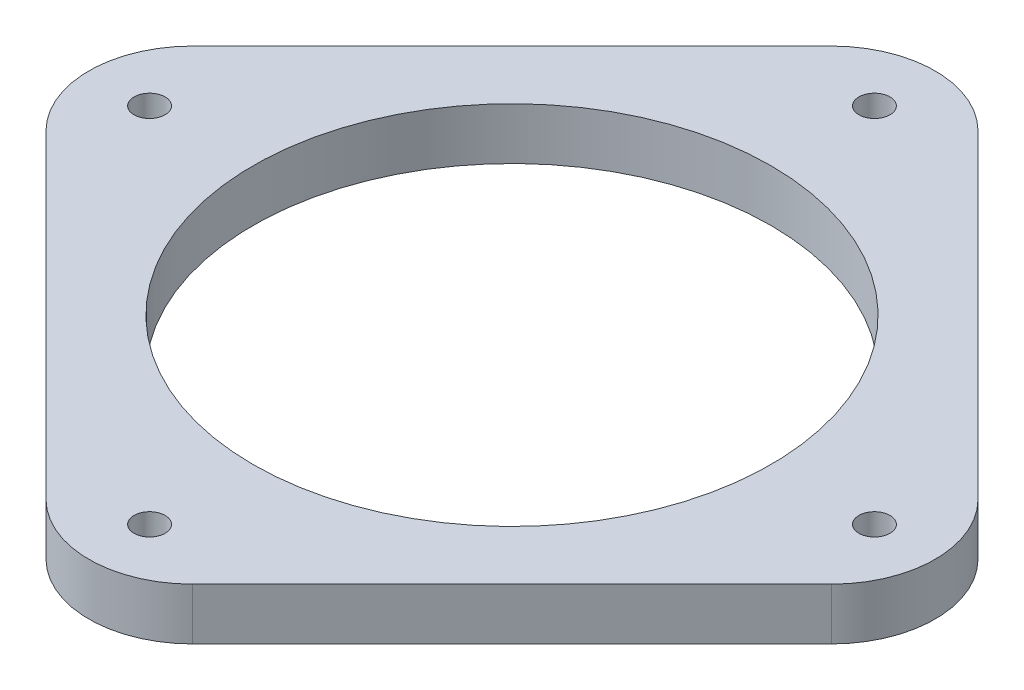
from build123d import *

# Parameters (mm, degrees)
CROQUIS1_R              = 25
CROQUIS1_R_2            = 1.5
SALIENTE_EXTRUIR1_DEPTH = 5


with BuildPart() as part:
    # Croquis1 → Saliente-Extruir1 (new body)
    with BuildSketch(Plane(origin=(0, 0, 0), x_dir=(1, 0, 0), z_dir=(0, 1, 0))):
        with BuildLine():
            Line((-37.928932188, -7.071067812), (-7.071067812, -37.928932188))
            ThreePointArc((-7.071067812, -37.928932188), (0, -40.857864376), (7.071067812, -37.928932188))
            Line((7.071067812, -37.928932188), (37.928932188, -7.071067812))
            ThreePointArc((37.928932188, -7.071067812), (40.857864376, 0), (37.928932188, 7.071067812))
            Line((37.928932188, 7.071067812), (7.071067812, 37.928932188))
            ThreePointArc((7.071067812, 37.928932188), (0, 40.857864376), (-7.071067812, 37.928932188))
            Line((-7.071067812, 37.928932188), (-37.928932188, 7.071067812))
            ThreePointArc((-37.928932188, 7.071067812), (-40.857864376, 0), (-37.928932188, -7.071067812))
        make_face()
        Circle(CROQUIS1_R, mode=Mode.SUBTRACT)
        with Locations((35, 0)):
            Circle(CROQUIS1_R_2, mode=Mode.SUBTRACT)
        with Locations((0, -35)):
            Circle(CROQUIS1_R_2, mode=Mode.SUBTRACT)
        with Locations((-35, 0)):
            Circle(CROQUIS1_R_2, mode=Mode.SUBTRACT)
        with Locations((0, 35)):
            Circle(CROQUIS1_R_2, mode=Mode.SUBTRACT)
    extrude(amount=SALIENTE_EXTRUIR1_DEPTH)


solid = part.part
